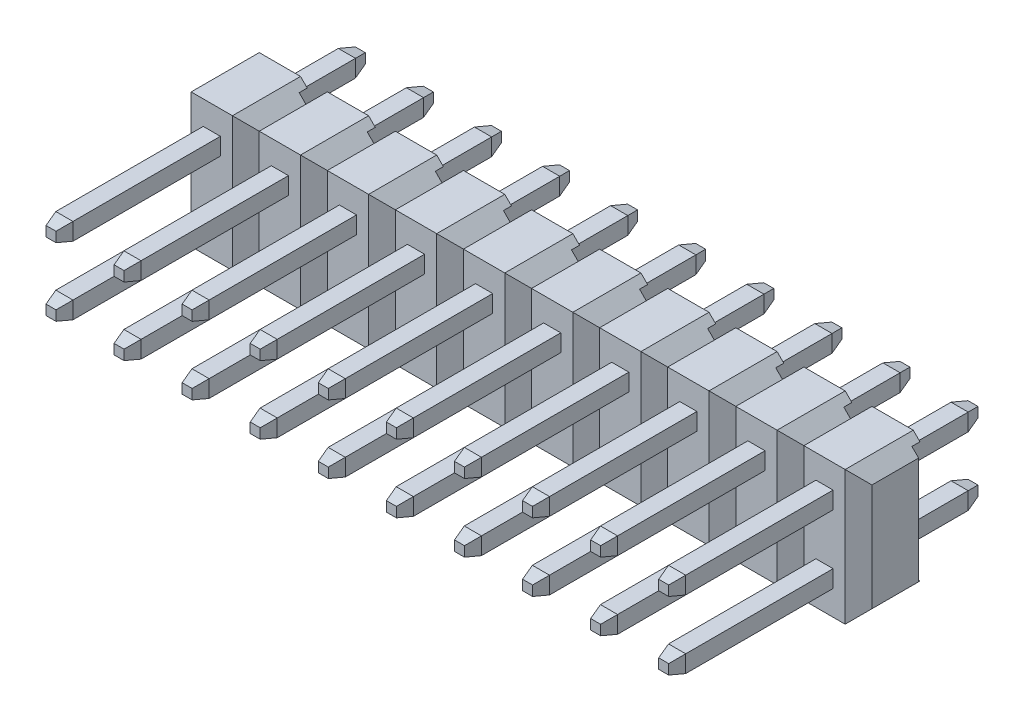
from build123d import *

# Parameters (mm, degrees)
SKETCH2_W             = 2.54
SKETCH2_H             = 5
BOSS_EXTRUDE1_DEPTH   = 2.54
SKETCH3_W             = 0.3
SKETCH3_H             = 4.5
CUT_EXTRUDE1_DEPTH    = 3.54
CHAMFER1_SIZE         = 0.5
CHAMFER2_SIZE         = 0.5
SKETCH4_W             = 0.64
SKETCH4_H             = 0.64
BOSS_EXTRUDE2_DEPTH   = 6
SKETCH6_W             = 0.64
SKETCH6_H             = 0.64
BOSS_EXTRUDE3_DEPTH   = 3.3
CHAMFER3_SIZE         = 0.5
CHAMFER3_SIZE2        = 0.133974596
CHAMFER3_PART_2_SIZE  = 0.5
CHAMFER3_PART_2_SIZE2 = 0.133974596
CHAMFER3_PART_3_SIZE  = 0.5
CHAMFER3_PART_3_SIZE2 = 0.133974596
CHAMFER3_PART_4_SIZE  = 0.5
CHAMFER3_PART_4_SIZE2 = 0.133974596
CHAMFER4_SIZE         = 0.5
CHAMFER4_SIZE2        = 0.133974596
CHAMFER4_PART_2_SIZE  = 0.5
CHAMFER4_PART_2_SIZE2 = 0.133974596
CHAMFER4_PART_3_SIZE  = 0.5
CHAMFER4_PART_3_SIZE2 = 0.133974596
CHAMFER4_PART_4_SIZE  = 0.5
CHAMFER4_PART_4_SIZE2 = 0.133974596
LPATTERN11_COUNT      = 2
LPATTERN11_PITCH      = 2.54
LPATTERN12_COUNT      = 10
LPATTERN12_PITCH      = 2.54
LPATTERN13_COUNT      = 10
LPATTERN13_PITCH      = 2.54


with BuildPart() as part:
    # Sketch2 → Boss-Extrude1 (new body)
    with BuildSketch(Plane.XY):
        with Locations((1.27, 2.5)):
            Rectangle(SKETCH2_W, SKETCH2_H)
    extrude(amount=BOSS_EXTRUDE1_DEPTH)

    # Sketch3 → Cut-Extrude1 (cut, through all)
    with BuildSketch(Plane.ZY):
        with Locations((0.15, 2.5)):
            Rectangle(SKETCH3_W, SKETCH3_H)
    extrude(amount=-CUT_EXTRUDE1_DEPTH, mode=Mode.SUBTRACT)

    # Chamfer1
    chamfer1_edges = [part.edges().sort_by_distance(p)[0] for p in [
        (2.54, 5, 1.27),
        (2.54, 0, 1.27),
        (0, 5, 1.27),
        (0, 0, 1.27),
    ]]
    chamfer(chamfer1_edges, length=CHAMFER1_SIZE)

    # Chamfer2
    chamfer2_edges = [part.edges().sort_by_distance(p)[0] for p in [
        (2.54, 2.5, 2.54),
        (0, 2.5, 2.54),
    ]]
    chamfer(chamfer2_edges, length=CHAMFER2_SIZE)


with BuildPart() as body_2:
    # Sketch4 → Boss-Extrude2 (new body)
    with BuildSketch(Plane.XY.offset(2.54)):
        with Locations((1.27, 1.25)):
            Rectangle(SKETCH4_W, SKETCH4_H)
    extrude(amount=BOSS_EXTRUDE2_DEPTH)

    # Chamfer3
    chamfer3_edges = [body_2.edges().sort_by_distance(p)[0] for p in [
        (1.59, 1.25, 8.54),
    ]]
    chamfer3_side = [body_2.faces().sort_by_distance(p)[0] for p in [
        (1.59, 1.25, 5.54),
    ]]
    chamfer(chamfer3_edges, length=CHAMFER3_SIZE, length2=CHAMFER3_SIZE2, reference=chamfer3_side[0])

    # Chamfer3 part 2
    chamfer3_part_2_edges = [body_2.edges().sort_by_distance(p)[0] for p in [
        (1.27, 1.57, 8.54),
    ]]
    chamfer3_part_2_side = [body_2.faces().sort_by_distance(p)[0] for p in [
        (1.27, 1.57, 5.54),
    ]]
    chamfer(chamfer3_part_2_edges, length=CHAMFER3_PART_2_SIZE, length2=CHAMFER3_PART_2_SIZE2, reference=chamfer3_part_2_side[0])

    # Chamfer3 part 3
    chamfer3_part_3_edges = [body_2.edges().sort_by_distance(p)[0] for p in [
        (0.95, 1.25, 8.54),
    ]]
    chamfer3_part_3_side = [body_2.faces().sort_by_distance(p)[0] for p in [
        (0.95, 1.25, 5.54),
    ]]
    chamfer(chamfer3_part_3_edges, length=CHAMFER3_PART_3_SIZE, length2=CHAMFER3_PART_3_SIZE2, reference=chamfer3_part_3_side[0])

    # Chamfer3 part 4
    chamfer3_part_4_edges = [body_2.edges().sort_by_distance(p)[0] for p in [
        (1.27, 0.93, 8.54),
    ]]
    chamfer3_part_4_side = [body_2.faces().sort_by_distance(p)[0] for p in [
        (1.27, 0.93, 5.54),
    ]]
    chamfer(chamfer3_part_4_edges, length=CHAMFER3_PART_4_SIZE, length2=CHAMFER3_PART_4_SIZE2, reference=chamfer3_part_4_side[0])


with BuildPart() as body_3:
    # Sketch6 → Boss-Extrude3 (new body)
    with BuildSketch(Plane(origin=(0, 0, 0.3), x_dir=(-1, 0, 0), z_dir=(0, 0, -1))):
        with Locations((-1.27, 1.25)):
            Rectangle(SKETCH6_W, SKETCH6_H)
    extrude(amount=BOSS_EXTRUDE3_DEPTH)

    # Chamfer4
    chamfer4_edges = [body_3.edges().sort_by_distance(p)[0] for p in [
        (0.95, 1.25, -3),
    ]]
    chamfer4_side = [body_3.faces().sort_by_distance(p)[0] for p in [
        (0.95, 1.25, -1.35),
    ]]
    chamfer(chamfer4_edges, length=CHAMFER4_SIZE, length2=CHAMFER4_SIZE2, reference=chamfer4_side[0])

    # Chamfer4 part 2
    chamfer4_part_2_edges = [body_3.edges().sort_by_distance(p)[0] for p in [
        (1.27, 1.57, -3),
    ]]
    chamfer4_part_2_side = [body_3.faces().sort_by_distance(p)[0] for p in [
        (1.27, 1.57, -1.35),
    ]]
    chamfer(chamfer4_part_2_edges, length=CHAMFER4_PART_2_SIZE, length2=CHAMFER4_PART_2_SIZE2, reference=chamfer4_part_2_side[0])

    # Chamfer4 part 3
    chamfer4_part_3_edges = [body_3.edges().sort_by_distance(p)[0] for p in [
        (1.59, 1.25, -3),
    ]]
    chamfer4_part_3_side = [body_3.faces().sort_by_distance(p)[0] for p in [
        (1.59, 1.25, -1.35),
    ]]
    chamfer(chamfer4_part_3_edges, length=CHAMFER4_PART_3_SIZE, length2=CHAMFER4_PART_3_SIZE2, reference=chamfer4_part_3_side[0])

    # Chamfer4 part 4
    chamfer4_part_4_edges = [body_3.edges().sort_by_distance(p)[0] for p in [
        (1.27, 0.93, -3),
    ]]
    chamfer4_part_4_side = [body_3.faces().sort_by_distance(p)[0] for p in [
        (1.27, 0.93, -1.35),
    ]]
    chamfer(chamfer4_part_4_edges, length=CHAMFER4_PART_4_SIZE, length2=CHAMFER4_PART_4_SIZE2, reference=chamfer4_part_4_side[0])


with BuildPart() as lpattern11_1:
    # LPattern11: pattern copy
    add(body_3.part.moved(Location(Vector(0, 1, 0) * (1 * LPATTERN11_PITCH))))


with BuildPart() as lpattern11_2:
    # LPattern11: pattern copy
    add(body_2.part.moved(Location(Vector(0, 1, 0) * (1 * LPATTERN11_PITCH))))


with BuildPart() as lpattern12_1:
    # LPattern12: pattern copy
    add(part.part.moved(Location(Vector(-1, 0, 0) * (1 * LPATTERN12_PITCH))))


with BuildPart() as lpattern12_2:
    # LPattern12: pattern copy
    add(part.part.moved(Location(Vector(-1, 0, 0) * (2 * LPATTERN12_PITCH))))


with BuildPart() as lpattern12_3:
    # LPattern12: pattern copy
    add(part.part.moved(Location(Vector(-1, 0, 0) * (3 * LPATTERN12_PITCH))))


with BuildPart() as lpattern12_4:
    # LPattern12: pattern copy
    add(part.part.moved(Location(Vector(-1, 0, 0) * (4 * LPATTERN12_PITCH))))


with BuildPart() as lpattern12_5:
    # LPattern12: pattern copy
    add(part.part.moved(Location(Vector(-1, 0, 0) * (5 * LPATTERN12_PITCH))))


with BuildPart() as lpattern12_6:
    # LPattern12: pattern copy
    add(part.part.moved(Location(Vector(-1, 0, 0) * (6 * LPATTERN12_PITCH))))


with BuildPart() as lpattern12_7:
    # LPattern12: pattern copy
    add(part.part.moved(Location(Vector(-1, 0, 0) * (7 * LPATTERN12_PITCH))))


with BuildPart() as lpattern12_8:
    # LPattern12: pattern copy
    add(part.part.moved(Location(Vector(-1, 0, 0) * (8 * LPATTERN12_PITCH))))


with BuildPart() as lpattern12_9:
    # LPattern12: pattern copy
    add(part.part.moved(Location(Vector(-1, 0, 0) * (9 * LPATTERN12_PITCH))))


with BuildPart() as lpattern13_1:
    # LPattern13: pattern copy
    add(body_3.part.moved(Location(Vector(-1, 0, 0) * (1 * LPATTERN13_PITCH))))


with BuildPart() as lpattern13_2:
    # LPattern13: pattern copy
    add(body_3.part.moved(Location(Vector(-1, 0, 0) * (2 * LPATTERN13_PITCH))))


with BuildPart() as lpattern13_3:
    # LPattern13: pattern copy
    add(body_3.part.moved(Location(Vector(-1, 0, 0) * (3 * LPATTERN13_PITCH))))


with BuildPart() as lpattern13_4:
    # LPattern13: pattern copy
    add(body_3.part.moved(Location(Vector(-1, 0, 0) * (4 * LPATTERN13_PITCH))))


with BuildPart() as lpattern13_5:
    # LPattern13: pattern copy
    add(body_3.part.moved(Location(Vector(-1, 0, 0) * (5 * LPATTERN13_PITCH))))


with BuildPart() as lpattern13_6:
    # LPattern13: pattern copy
    add(body_3.part.moved(Location(Vector(-1, 0, 0) * (6 * LPATTERN13_PITCH))))


with BuildPart() as lpattern13_7:
    # LPattern13: pattern copy
    add(body_3.part.moved(Location(Vector(-1, 0, 0) * (7 * LPATTERN13_PITCH))))


with BuildPart() as lpattern13_8:
    # LPattern13: pattern copy
    add(body_3.part.moved(Location(Vector(-1, 0, 0) * (8 * LPATTERN13_PITCH))))


with BuildPart() as lpattern13_9:
    # LPattern13: pattern copy
    add(body_3.part.moved(Location(Vector(-1, 0, 0) * (9 * LPATTERN13_PITCH))))


with BuildPart() as lpattern13_10:
    # LPattern13: pattern copy
    add(lpattern11_1.part.moved(Location(Vector(-1, 0, 0) * (1 * LPATTERN13_PITCH))))


with BuildPart() as lpattern13_11:
    # LPattern13: pattern copy
    add(lpattern11_1.part.moved(Location(Vector(-1, 0, 0) * (2 * LPATTERN13_PITCH))))


with BuildPart() as lpattern13_12:
    # LPattern13: pattern copy
    add(lpattern11_1.part.moved(Location(Vector(-1, 0, 0) * (3 * LPATTERN13_PITCH))))


with BuildPart() as lpattern13_13:
    # LPattern13: pattern copy
    add(lpattern11_1.part.moved(Location(Vector(-1, 0, 0) * (4 * LPATTERN13_PITCH))))


with BuildPart() as lpattern13_14:
    # LPattern13: pattern copy
    add(lpattern11_1.part.moved(Location(Vector(-1, 0, 0) * (5 * LPATTERN13_PITCH))))


with BuildPart() as lpattern13_15:
    # LPattern13: pattern copy
    add(lpattern11_1.part.moved(Location(Vector(-1, 0, 0) * (6 * LPATTERN13_PITCH))))


with BuildPart() as lpattern13_16:
    # LPattern13: pattern copy
    add(lpattern11_1.part.moved(Location(Vector(-1, 0, 0) * (7 * LPATTERN13_PITCH))))


with BuildPart() as lpattern13_17:
    # LPattern13: pattern copy
    add(lpattern11_1.part.moved(Location(Vector(-1, 0, 0) * (8 * LPATTERN13_PITCH))))


with BuildPart() as lpattern13_18:
    # LPattern13: pattern copy
    add(lpattern11_1.part.moved(Location(Vector(-1, 0, 0) * (9 * LPATTERN13_PITCH))))


with BuildPart() as lpattern13_19:
    # LPattern13: pattern copy
    add(body_2.part.moved(Location(Vector(-1, 0, 0) * (1 * LPATTERN13_PITCH))))


with BuildPart() as lpattern13_20:
    # LPattern13: pattern copy
    add(body_2.part.moved(Location(Vector(-1, 0, 0) * (2 * LPATTERN13_PITCH))))


with BuildPart() as lpattern13_21:
    # LPattern13: pattern copy
    add(body_2.part.moved(Location(Vector(-1, 0, 0) * (3 * LPATTERN13_PITCH))))


with BuildPart() as lpattern13_22:
    # LPattern13: pattern copy
    add(body_2.part.moved(Location(Vector(-1, 0, 0) * (4 * LPATTERN13_PITCH))))


with BuildPart() as lpattern13_23:
    # LPattern13: pattern copy
    add(body_2.part.moved(Location(Vector(-1, 0, 0) * (5 * LPATTERN13_PITCH))))


with BuildPart() as lpattern13_24:
    # LPattern13: pattern copy
    add(body_2.part.moved(Location(Vector(-1, 0, 0) * (6 * LPATTERN13_PITCH))))


with BuildPart() as lpattern13_25:
    # LPattern13: pattern copy
    add(body_2.part.moved(Location(Vector(-1, 0, 0) * (7 * LPATTERN13_PITCH))))


with BuildPart() as lpattern13_26:
    # LPattern13: pattern copy
    add(body_2.part.moved(Location(Vector(-1, 0, 0) * (8 * LPATTERN13_PITCH))))


with BuildPart() as lpattern13_27:
    # LPattern13: pattern copy
    add(body_2.part.moved(Location(Vector(-1, 0, 0) * (9 * LPATTERN13_PITCH))))


with BuildPart() as lpattern13_28:
    # LPattern13: pattern copy
    add(lpattern11_2.part.moved(Location(Vector(-1, 0, 0) * (1 * LPATTERN13_PITCH))))


with BuildPart() as lpattern13_29:
    # LPattern13: pattern copy
    add(lpattern11_2.part.moved(Location(Vector(-1, 0, 0) * (2 * LPATTERN13_PITCH))))


with BuildPart() as lpattern13_30:
    # LPattern13: pattern copy
    add(lpattern11_2.part.moved(Location(Vector(-1, 0, 0) * (3 * LPATTERN13_PITCH))))


with BuildPart() as lpattern13_31:
    # LPattern13: pattern copy
    add(lpattern11_2.part.moved(Location(Vector(-1, 0, 0) * (4 * LPATTERN13_PITCH))))


with BuildPart() as lpattern13_32:
    # LPattern13: pattern copy
    add(lpattern11_2.part.moved(Location(Vector(-1, 0, 0) * (5 * LPATTERN13_PITCH))))


with BuildPart() as lpattern13_33:
    # LPattern13: pattern copy
    add(lpattern11_2.part.moved(Location(Vector(-1, 0, 0) * (6 * LPATTERN13_PITCH))))


with BuildPart() as lpattern13_34:
    # LPattern13: pattern copy
    add(lpattern11_2.part.moved(Location(Vector(-1, 0, 0) * (7 * LPATTERN13_PITCH))))


with BuildPart() as lpattern13_35:
    # LPattern13: pattern copy
    add(lpattern11_2.part.moved(Location(Vector(-1, 0, 0) * (8 * LPATTERN13_PITCH))))


with BuildPart() as lpattern13_36:
    # LPattern13: pattern copy
    add(lpattern11_2.part.moved(Location(Vector(-1, 0, 0) * (9 * LPATTERN13_PITCH))))


solid = Compound([part.part, body_2.part, body_3.part, lpattern11_1.part, lpattern11_2.part, lpattern12_1.part, lpattern12_2.part, lpattern12_3.part, lpattern12_4.part, lpattern12_5.part, lpattern12_6.part, lpattern12_7.part, lpattern12_8.part, lpattern12_9.part, lpattern13_1.part, lpattern13_2.part, lpattern13_3.part, lpattern13_4.part, lpattern13_5.part, lpattern13_6.part, lpattern13_7.part, lpattern13_8.part, lpattern13_9.part, lpattern13_10.part, lpattern13_11.part, lpattern13_12.part, lpattern13_13.part, lpattern13_14.part, lpattern13_15.part, lpattern13_16.part, lpattern13_17.part, lpattern13_18.part, lpattern13_19.part, lpattern13_20.part, lpattern13_21.part, lpattern13_22.part, lpattern13_23.part, lpattern13_24.part, lpattern13_25.part, lpattern13_26.part, lpattern13_27.part, lpattern13_28.part, lpattern13_29.part, lpattern13_30.part, lpattern13_31.part, lpattern13_32.part, lpattern13_33.part, lpattern13_34.part, lpattern13_35.part, lpattern13_36.part])
